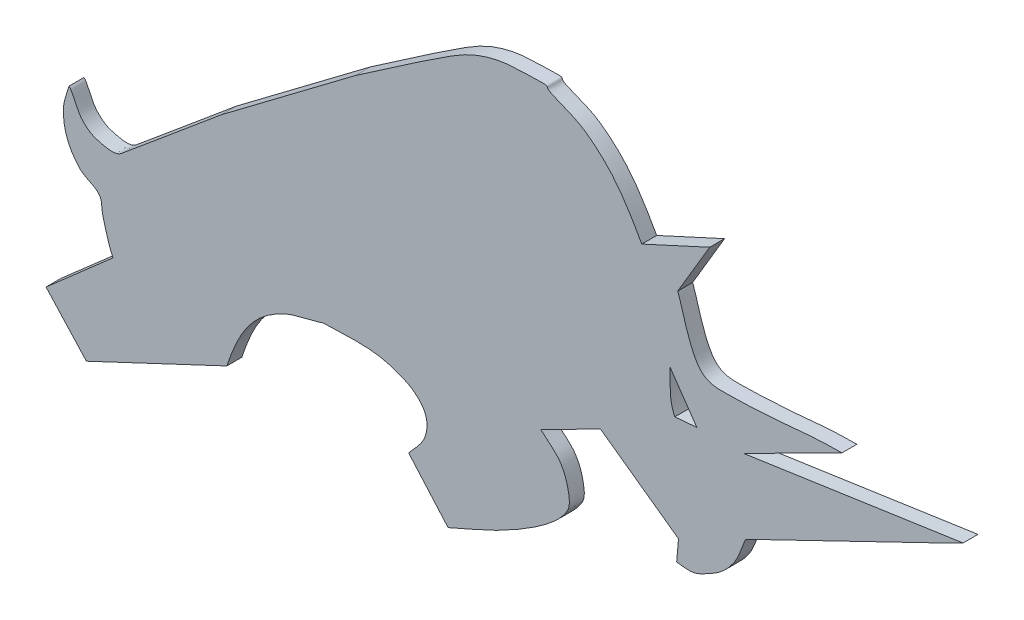
from build123d import *

# Parameters (mm, degrees)
BOSS_EXTRUDE2_DEPTH = 0.508


with BuildPart() as part:
    # Sketch1 → Boss-Extrude2 (new body)
    with BuildSketch(Plane.XY):
        with BuildLine():
            add(Edge.make_bspline(
                [(2.65625, 4.34375), (2.48977876, 4.676692479), (2.412867315, 5.047795303), (2.3125, 5.40625), (2.260711144, 5.5912102), (2.305749117, 5.81739113), (2.1875, 5.96875), (2.025644238, 6.175925375), (1.714515242, 6.217748608), (1.53125, 6.40625), (1.341900203, 6.601009792), (1.189126866, 6.839411691), (1.09375, 7.09375), (0.997535254, 7.350322657), (0.957797969, 7.632449236), (0.96875, 7.90625), (0.979049528, 8.163738193), (1.09375, 8.40625), (1.15625, 8.65625)],
                knots=[0, 0, 0, 0, 1, 1, 1, 2, 2, 2, 3, 3, 3, 4, 4, 4, 5, 5, 5, 6, 6, 6, 6], degree=3))
            add(Edge.make_bspline(
                [(1.15625, 8.65625), (1.177083333, 8.635416667), (1.203904558, 8.61919933), (1.21875, 8.59375), (1.350280955, 8.368268362), (1.424862413, 8.105296085), (1.59375, 7.90625), (1.724604477, 7.752028653), (1.899638232, 7.6193132), (2.09375, 7.5625), (2.363676146, 7.483497226), (2.720958822, 7.383024429), (2.9375, 7.5625), (4.076289716, 8.506361747), (5.208333333, 9.458333333), (6.34375, 10.40625)],
                knots=[0, 0, 0, 0, 1, 1, 1, 2, 2, 2, 3, 3, 3, 4, 4, 4, 5, 5, 5, 5], degree=3))
            Line((6.34375, 10.40625), (10.90625, 13.84375))
            add(Edge.make_bspline(
                [(10.90625, 13.84375), (12, 14.583333333), (13.07291853, 15.354700088), (14.1875, 16.0625), (14.502103045, 16.262284416), (14.835012901, 16.441496966), (15.1875, 16.5625), (15.539159987, 16.6832191), (15.909735823, 16.766584967), (16.28125, 16.78125), (17.935308389, 16.846541779), (17.159713529, 16.837702387), (17.625, 16.625), (17.968413184, 16.468011116), (18.339772547, 16.362211517), (18.65625, 16.15625), (19.002845723, 15.930687704), (19.316835055, 15.650873848), (19.59375, 15.34375), (20.021301944, 14.869556026), (20.343226514, 14.306486197), (20.65625, 13.75)],
                knots=[0, 0, 0, 0, 1, 1, 1, 2, 2, 2, 3, 3, 3, 4, 4, 4, 5, 5, 5, 6, 6, 6, 7, 7, 7, 7], degree=3))
            Line((20.65625, 13.75), (22.96875, 14.8125))
            Line((22.96875, 14.8125), (21.875, 12.96875))
            add(Edge.make_bspline(
                [(21.875, 12.96875), (21.885416667, 12.947916667), (21.898743711, 12.928299724), (21.90625, 12.90625), (22.065482439, 12.438504711), (22.171067492, 11.950057949), (22.375, 11.5), (22.476466528, 11.27607387), (22.60370986, 11.036038465), (22.8125, 10.90625), (23.019028808, 10.777867228), (23.288102093, 10.77732826), (23.53125, 10.78125), (25.608662384, 10.814756651), (25.978778222, 11), (27.46875, 11)],
                knots=[0, 0, 0, 0, 1, 1, 1, 2, 2, 2, 3, 3, 3, 4, 4, 4, 5, 5, 5, 5], degree=3))
            Line((27.46875, 11), (24.125, 9.3125))
            Line((24.125, 9.3125), (31.59375, 10.40625))
            Line((31.59375, 10.40625), (30.84375, 10.03125))
            Line((30.84375, 10.03125), (24.1875, 6.8125))
            add(Edge.make_bspline(
                [(24.1875, 6.8125), (24.052083333, 6.510416667), (23.969973698, 6.178234153), (23.78125, 5.90625), (23.609037866, 5.658061924), (23.384473565, 5.435936164), (23.125, 5.28125), (22.427598099, 4.865491174), (22.384146393, 4.914710361), (21.84375, 4.96875)],
                knots=[0, 0, 0, 0, 1, 1, 1, 2, 2, 2, 3, 3, 3, 3], degree=3))
            Line((21.84375, 4.96875), (21.90625, 5.6875))
            Line((21.90625, 5.6875), (19.25, 7.59375))
            Line((19.25, 7.59375), (17.21875, 6.5625))
            add(Edge.make_bspline(
                [(17.21875, 6.5625), (17.4375, 6.354166667), (17.702153476, 6.185246684), (17.875, 5.9375), (18.022206697, 5.726503734), (18.108111165, 5.471478884), (18.15625, 5.21875), (18.193333861, 5.02405973), (18.222908021, 4.797318117), (18.125, 4.625), (17.94666545, 4.311131192), (17.662331963, 4.062284169), (17.375, 3.84375), (16.917108738, 3.495494674), (16.41490808, 3.206225023), (15.90625, 2.9375), (15.308641074, 2.621782077), (14.677083333, 2.375), (14.0625, 2.09375)],
                knots=[0, 0, 0, 0, 1, 1, 1, 2, 2, 2, 3, 3, 3, 4, 4, 4, 5, 5, 5, 6, 6, 6, 6], degree=3))
            Line((14.0625, 2.09375), (12.71875, 3.625))
            add(Edge.make_bspline(
                [(12.71875, 3.625), (12.885416667, 3.833333333), (13.094490322, 4.013906612), (13.21875, 4.25), (13.308207707, 4.419969644), (13.355369519, 4.620777941), (13.34375, 4.8125), (13.333569504, 4.980478183), (13.263068013, 5.15121068), (13.15625, 5.28125), (13.014749824, 5.453511083), (12.828216756, 5.595853228), (12.625, 5.6875), (12.288471698, 5.839267666), (11.92945859, 5.95967488), (11.5625, 6), (10.972302868, 6.064856828), (10.374914734, 6.010062114), (9.78125, 6), (9.75796097, 5.999605271), (9.741060049, 5.975443015), (9.71875, 5.96875), (9.324044945, 5.850338483), (8.90852108, 5.790770626), (8.53125, 5.625), (7.363041987, 5.111696479), (6.911893138, 4.235679413), (6.53125, 3.09375)],
                knots=[0, 0, 0, 0, 1, 1, 1, 2, 2, 2, 3, 3, 3, 4, 4, 4, 5, 5, 5, 6, 6, 6, 7, 7, 7, 8, 8, 8, 9, 9, 9, 9], degree=3))
            Line((6.53125, 3.09375), (1.75, 0.84375))
            Line((1.75, 0.84375), (0.375, 2.34375))
            Line((0.375, 2.34375), (2.65625, 4.34375))
        make_face()
        with BuildLine():
            Line((22.53125, 9.28125), (21.78125, 9.21875))
            add(Edge.make_bspline(
                [(21.78125, 9.21875), (21.570814417, 9.639621166), (21.625, 10.134759638), (21.625, 10.59375)],
                knots=[0, 0, 0, 0, 1, 1, 1, 1], degree=3))
            Line((21.625, 10.59375), (22.53125, 9.28125))
        make_face(mode=Mode.SUBTRACT)
    extrude(amount=BOSS_EXTRUDE2_DEPTH)


solid = part.part
